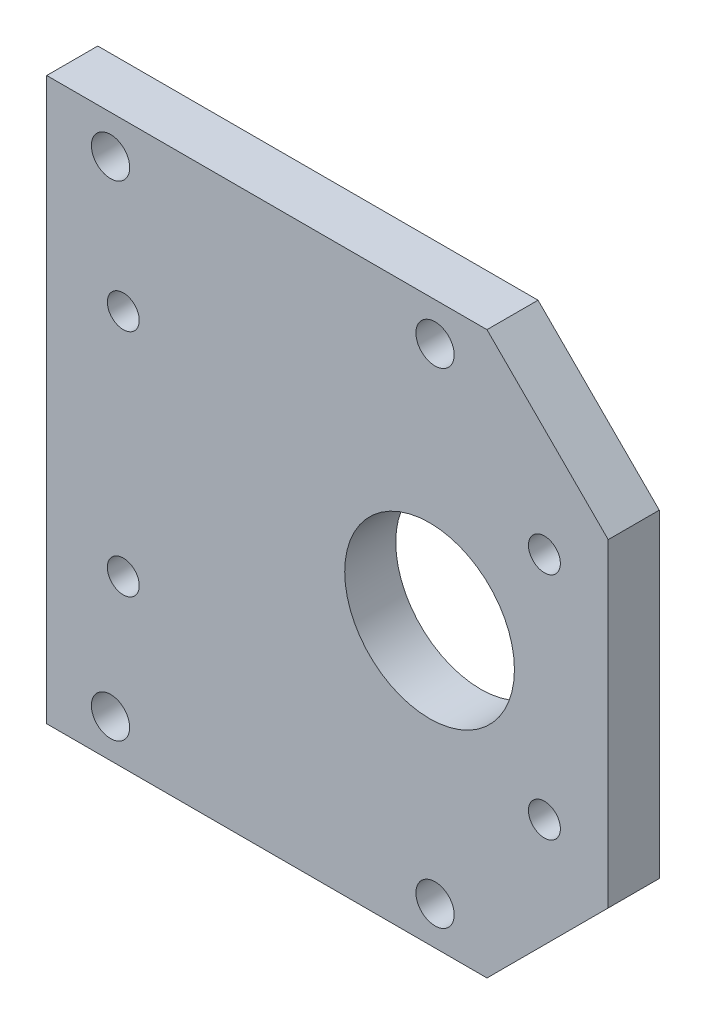
from build123d import *

# Parameters (mm, degrees)
SKETCH1_R           = 6.65
SKETCH1_R_2         = 1.25
BOSS_EXTRUDE1_DEPTH = 4
SKETCH2_R           = 1.5
CUT_EXTRUDE1_DEPTH  = 5


with BuildPart() as part:
    # Sketch1 → Boss-Extrude1 (new body)
    with BuildSketch(Plane.XY):
        Polygon((22, 12.5), (22, -12.5), (12.5, -22), (-22, -22), (-22, 22), (12.5, 22), align=None)
        with Locations((8, 0)):
            Circle(SKETCH1_R, mode=Mode.SUBTRACT)
        with Locations((17, 9)):
            Circle(SKETCH1_R_2, mode=Mode.SUBTRACT)
        with Locations((17, -9)):
            Circle(SKETCH1_R_2, mode=Mode.SUBTRACT)
        with Locations((-16, 9)):
            Circle(SKETCH1_R_2, mode=Mode.SUBTRACT)
        with Locations((-16, -9)):
            Circle(SKETCH1_R_2, mode=Mode.SUBTRACT)
    extrude(amount=BOSS_EXTRUDE1_DEPTH)

    # Sketch2 → Cut-Extrude1 (cut, through all)
    with BuildSketch(Plane.XY.offset(4)):
        with Locations((-17, -19)):
            Circle(SKETCH2_R)
        with Locations((8.428932188, -19)):
            Circle(SKETCH2_R)
        with Locations((-17, 19)):
            Circle(SKETCH2_R)
        with Locations((8.428932188, 19)):
            Circle(SKETCH2_R)
    extrude(amount=-CUT_EXTRUDE1_DEPTH, mode=Mode.SUBTRACT)


solid = part.part
